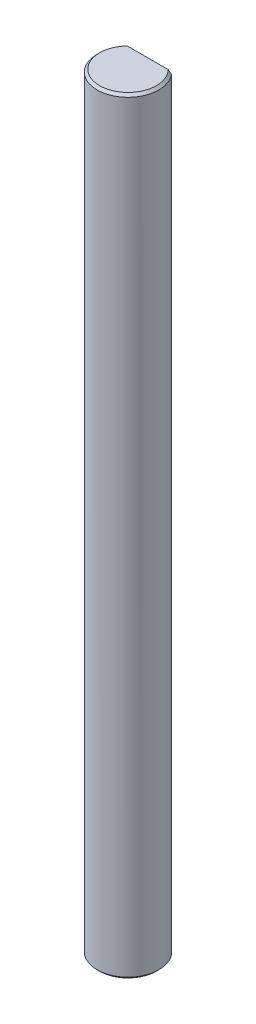
from build123d import *

# Parameters (mm, degrees)
CROQUIS1_R              = 2.5
SALIENTE_EXTRUIR1_DEPTH = 62
CORTAR_EXTRUIR1_DEPTH   = 17.5
CHAFL_N1_SIZE           = 0.2


with BuildPart() as part:
    # Croquis1 → Saliente-Extruir1 (new body)
    with BuildSketch(Plane(origin=(0, 0, 0), x_dir=(1, 0, 0), z_dir=(0, 1, 0))):
        Circle(CROQUIS1_R)
    extrude(amount=SALIENTE_EXTRUIR1_DEPTH)

    # Croquis2 → Cortar-Extruir1 (cut)
    with BuildSketch(Plane(origin=(0, 62, 0), x_dir=(1, 0, 0), z_dir=(0, 1, 0))):
        with BuildLine():
            Line((-1.920937271, 1.6), (1.920937271, 1.6))
            ThreePointArc((1.920937271, 1.6), (0, 2.5), (-1.920937271, 1.6))
        make_face()
    extrude(amount=-CORTAR_EXTRUIR1_DEPTH, mode=Mode.SUBTRACT)

    # Chaflán1
    chafl_n1_edges = [part.edges().sort_by_distance(p)[0] for p in [
        (-0.850781059, 62, 2.350781059),
        (-2.5, 0, 0),
    ]]
    chamfer(chafl_n1_edges, length=CHAFL_N1_SIZE)


solid = part.part
